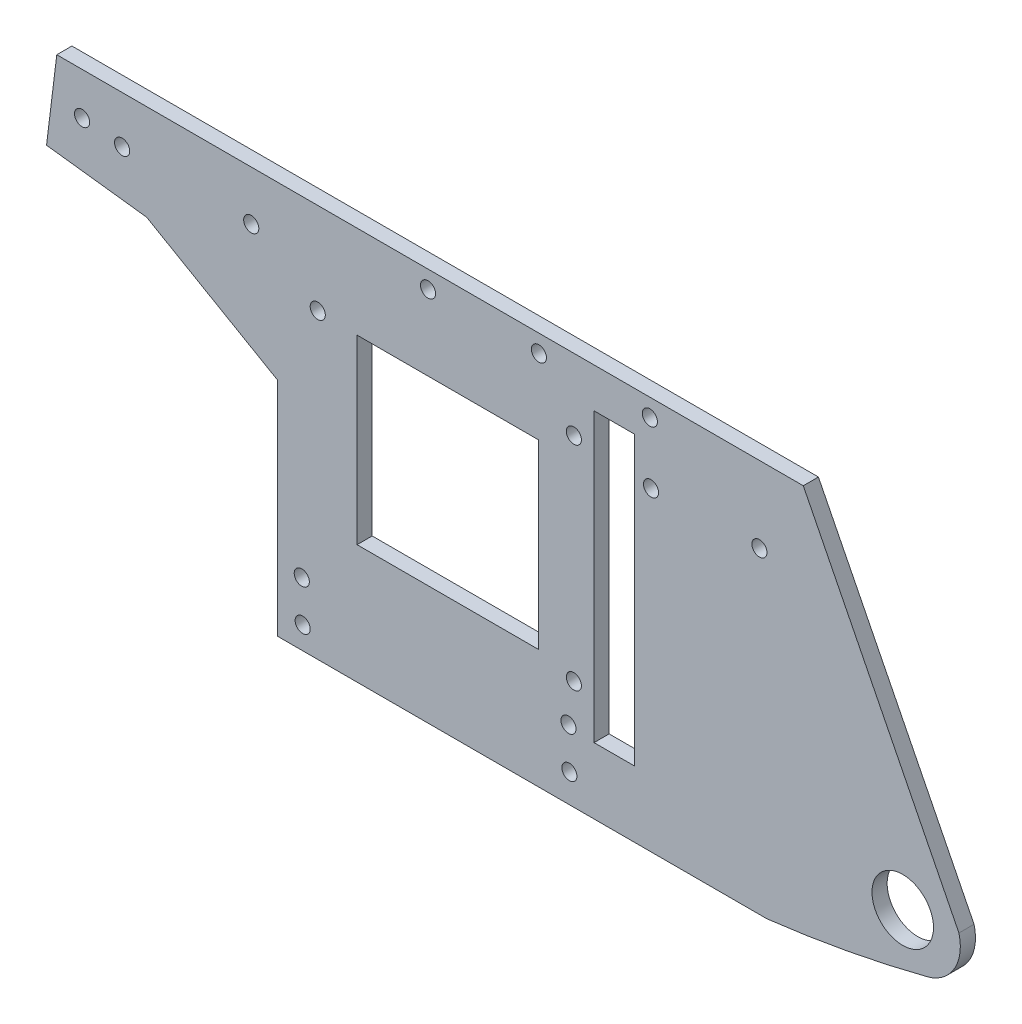
from build123d import *

# Parameters (mm, degrees)
EXTRUDE_1_DEPTH     = 3
CUT_EXTRUDE_1_REACH = 5
SKETCH_2_R          = 6.1
SKETCH_2_W          = 36
SKETCH_2_H          = 36
MM_CLEARANCE_1_D    = 3
MM_CLEARANCE_4_D    = 3
MM_PRESS_1_D        = 3
MM_PRESS_2_D        = 3
MM_PRESS_4_D        = 3


with BuildPart() as part:
    # 草图1 → 凸台-拉伸1 (new body)
    with BuildSketch(Plane.XY):
        with BuildLine():
            Line((30.58739299, 31.55542954), (153.948275504, 31.55542954))
            Line((153.948275504, 31.55542954), (184.822670137, -29.838251263))
            ThreePointArc((184.822670137, -29.838251263), (183.892664178, -36.470729041), (178.540104648, -40.496245038))
            ThreePointArc((178.540104648, -40.496245038), (162.746691749, -43.998966844), (146.755444956, -46.44457046))
            Line((146.755444956, -46.44457046), (49.675444956, -46.44457046))
            Line((49.675444956, -46.44457046), (49.675444956, -2.44457046))
            Line((49.675444956, -2.44457046), (23.694682842, 12.55542954))
            Line((23.694682842, 12.55542954), (3.843759809, 14.992816408))
            Line((3.843759809, 14.992816408), (5.87739299, 31.55542954))
            Line((5.87739299, 31.55542954), (30.58739299, 31.55542954))
        make_face()
    extrude(amount=EXTRUDE_1_DEPTH)

    # 草图2 → 切除-拉伸1 (cut, up to next)
    with BuildSketch(Plane.XY.offset(3), mode=Mode.PRIVATE) as cut_extrude_1_sk1:
        with Locations((173.675444956, -31.44457046)):
            Circle(SKETCH_2_R)
    cut_extrude_1_tool1 = extrude(cut_extrude_1_sk1.sketch, amount=-CUT_EXTRUDE_1_REACH, mode=Mode.PRIVATE) & part.part
    add(cut_extrude_1_tool1.solids().sort_by_distance((173.675445, -31.44457, 3))[0], mode=Mode.SUBTRACT)
    # 草图2 → 切除-拉伸1 (cut, up to next)
    with BuildSketch(Plane.XY.offset(3), mode=Mode.PRIVATE) as cut_extrude_1_sk2:
        with Locations((83.439887491, -4.827295438)):
            Rectangle(SKETCH_2_W, SKETCH_2_H)
    cut_extrude_1_tool2 = extrude(cut_extrude_1_sk2.sketch, amount=-CUT_EXTRUDE_1_REACH, mode=Mode.PRIVATE) & part.part
    add(cut_extrude_1_tool2.solids().sort_by_distance((83.439887, -4.827295, 3))[0], mode=Mode.SUBTRACT)
    # 草图2 → 切除-拉伸1 (cut, up to next)
    with BuildSketch(Plane.XY.offset(3), mode=Mode.PRIVATE) as cut_extrude_1_sk3:
        Polygon((112.439887491, -4.827295438), (112.439887491, -33.327295438), (120.439887491, -33.327295438), (120.439887491, 23.672704562), (112.439887491, 23.672704562), align=None)
    cut_extrude_1_tool3 = extrude(cut_extrude_1_sk3.sketch, amount=-CUT_EXTRUDE_1_REACH, mode=Mode.PRIVATE) & part.part
    add(cut_extrude_1_tool3.solids().sort_by_distance((116.439887, -4.827295, 3))[0], mode=Mode.SUBTRACT)

    # 大小mm Clearance 暗销孔1 (through all)
    with Locations(Plane(origin=(141.510624827, 151.85923203, 3), x_dir=(-0.999780146, -0.020968043, 0), z_dir=(0, 0, 1))):
        with Locations((20.591231353, 123.39816829), (42.591231353, 122.936763059), (64.581557509, 122.475560716)):
            Hole(MM_CLEARANCE_1_D / 2)

    # 大小mm Clearance 暗销孔4 (through all)
    with Locations(Plane(origin=(141.510624827, 151.85923203, 3), x_dir=(-0.999780146, -0.020968043, 0), z_dir=(0, 0, 1))):
        with Locations((20.608818994, 135.452556109), (-0.900285243, 135.452556109)):
            Hole(MM_CLEARANCE_4_D / 2)

    # 大小mm Press 暗销孔1 (through all)
    with Locations(Plane(origin=(141.673702765, 151.858231724, 3), x_dir=(-0.99978014, -0.020968354, 0), z_dir=(0, 0, 1))):
        with Locations((36.045400202, 133.709111751), (36.930668673, 175.919093371)):
            Hole(MM_PRESS_1_D / 2)

    # 大小mm Press 暗销孔2 (through all)
    with Locations(Plane(origin=(143.54728393, 150.625368255, 3), x_dir=(-0.99975237, -0.022253058, 0), z_dir=(0, 0, 1))):
        with Locations((88.938953066, 135.227377046), (101.942467158, 126.647536361), (127.53759353, 125.598807912), (135.454300746, 124.4473971)):
            Hole(MM_PRESS_2_D / 2)

    # 大小mm Press 暗销孔4 (through all)
    with Locations(Plane(origin=(143.54728393, 150.625368255, 3), x_dir=(-0.99975237, -0.022253058, 0), z_dir=(0, 0, 1))):
        with Locations((93.161367469, 190.578219389), (93.161367469, 182.547127137), (40.245392963, 190.578219389), (40.245392963, 182.547127137)):
            Hole(MM_PRESS_4_D / 2)


solid = part.part
